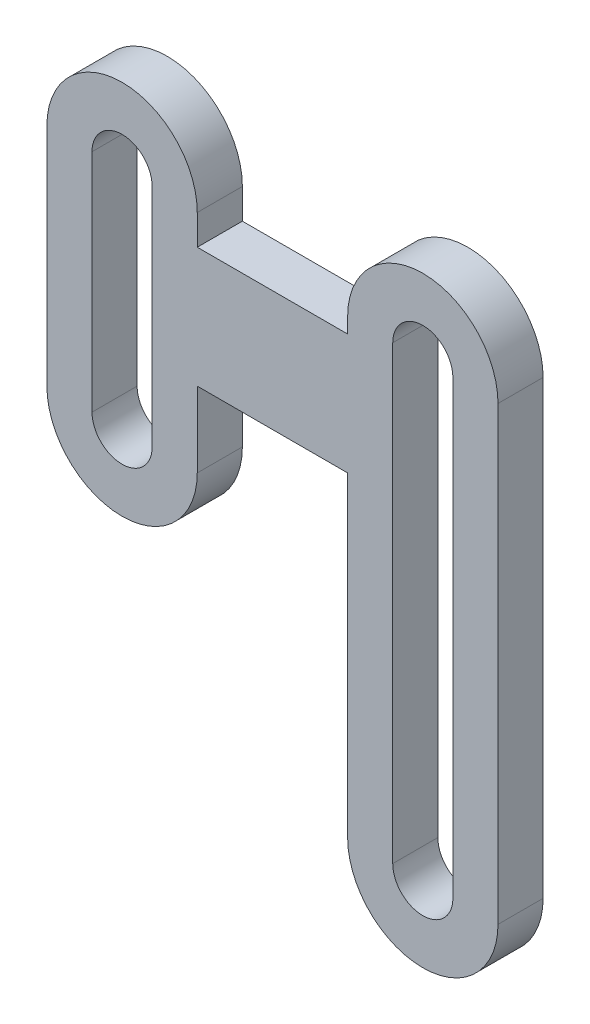
from build123d import *

# Parameters (mm, degrees)
RESSALTO_EXTRUS_O1_DEPTH = 3


with BuildPart() as part:
    # Esboço1 → Ressalto-extrusão1 (new body)
    with BuildSketch(Plane.XY):
        with BuildLine():
            Line((-5, 15), (-5, 30))
            ThreePointArc((-5, 30), (0, 35), (5, 30))
            Line((5, 30), (5, 28))
            Line((5, 28), (15, 28))
            Line((15, 28), (15, 29))
            ThreePointArc((15, 29), (20, 34), (25, 29))
            Line((25, 29), (25, -1))
            ThreePointArc((25, -1), (20, -6), (15, -1))
            Line((15, -1), (15, 20))
            Line((15, 20), (5, 20))
            Line((5, 20), (5, 15))
            ThreePointArc((5, 15), (0, 10), (-5, 15))
        make_face()
        with BuildLine():
            Line((2, 30), (2, 15))
            ThreePointArc((2, 15), (0, 13), (-2, 15))
            Line((-2, 15), (-2, 30))
            ThreePointArc((-2, 30), (0, 32), (2, 30))
        make_face(mode=Mode.SUBTRACT)
        with BuildLine():
            Line((22, 29), (22, -1))
            ThreePointArc((22, -1), (20, -3), (18, -1))
            Line((18, -1), (18, 29))
            ThreePointArc((18, 29), (20, 31), (22, 29))
        make_face(mode=Mode.SUBTRACT)
    extrude(amount=RESSALTO_EXTRUS_O1_DEPTH)


solid = part.part
